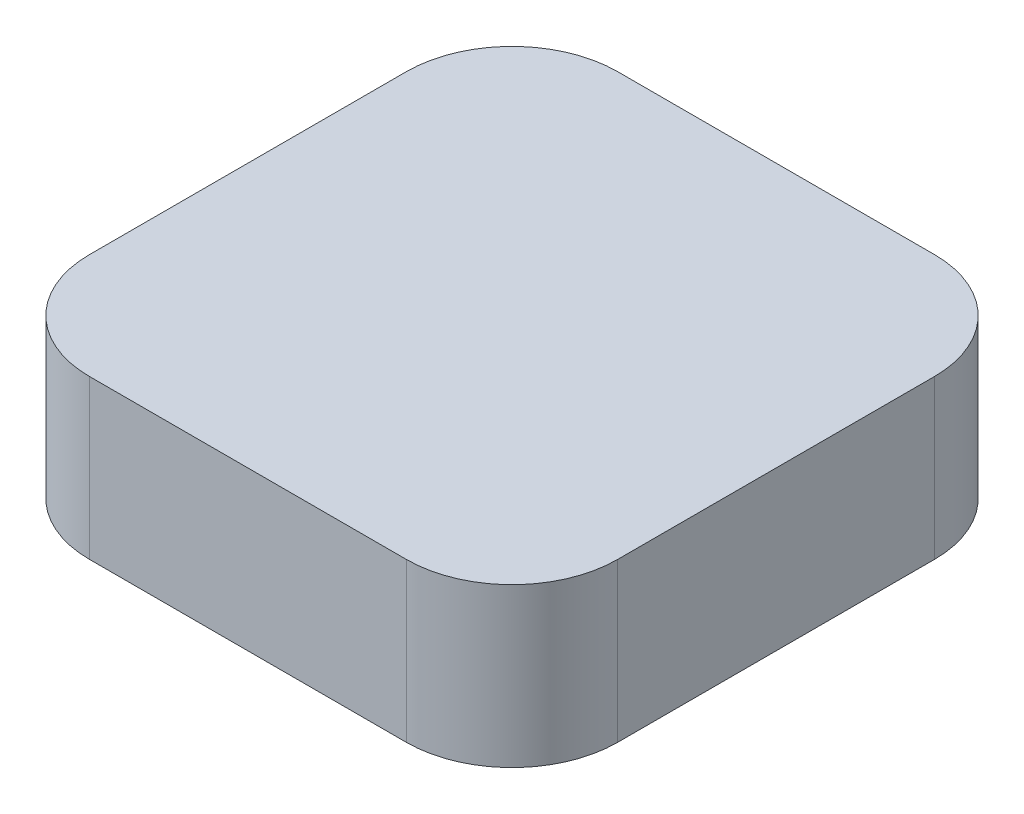
from build123d import *

# Parameters (mm, degrees)
BOSS_EXTRUDE1_DEPTH = 3


with BuildPart() as part:
    # Sketch1 → Boss-Extrude1 (new body)
    with BuildSketch(Plane(origin=(0, 0, 0), x_dir=(1, 0, 0), z_dir=(0, 1, 0))):
        with BuildLine():
            Line((-2.538461538, 3.576923077), (3.461538462, 3.576923077))
            ThreePointArc((3.461538462, 3.576923077), (4.875752024, 2.991136639), (5.461538462, 1.576923077))
            Line((5.461538462, 1.576923077), (5.461538462, -4.423076923))
            ThreePointArc((5.461538462, -4.423076923), (4.875752024, -5.837290485), (3.461538462, -6.423076923))
            Line((3.461538462, -6.423076923), (-2.538461538, -6.423076923))
            ThreePointArc((-2.538461538, -6.423076923), (-3.952675101, -5.837290485), (-4.538461538, -4.423076923))
            Line((-4.538461538, -4.423076923), (-4.538461538, 1.576923077))
            ThreePointArc((-4.538461538, 1.576923077), (-3.952675101, 2.991136639), (-2.538461538, 3.576923077))
        make_face()
    extrude(amount=BOSS_EXTRUDE1_DEPTH)


solid = part.part
